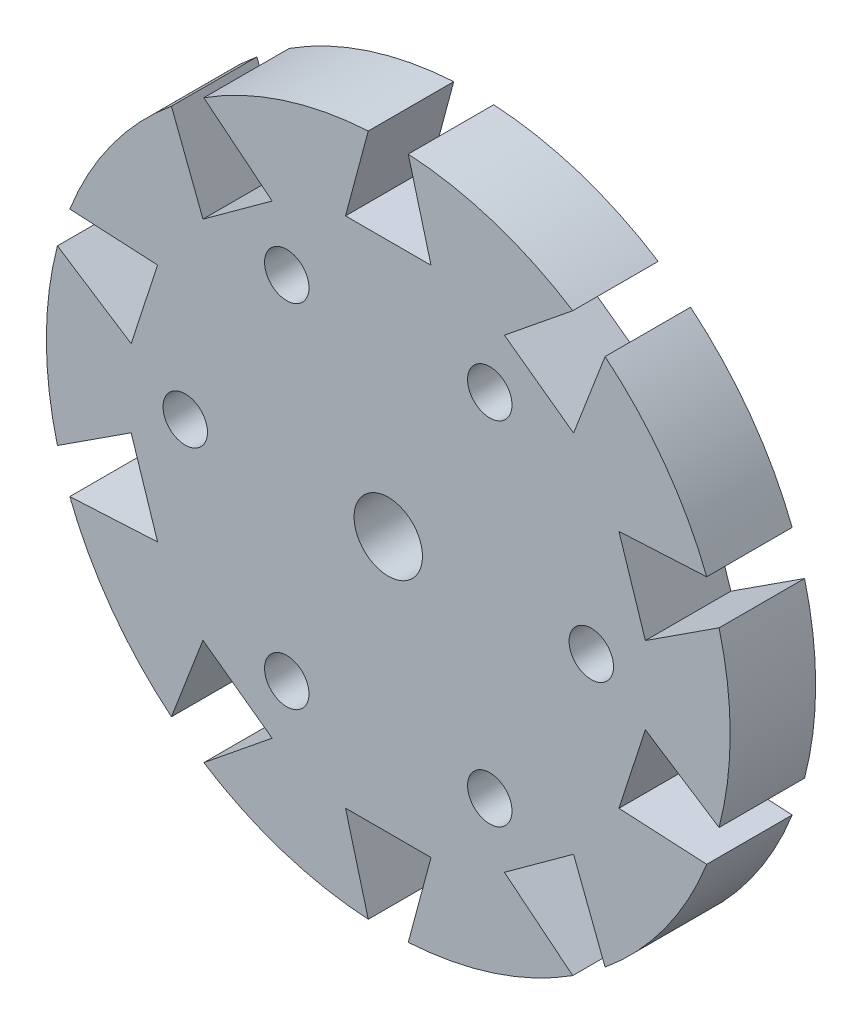
from build123d import *

# Parameters (mm, degrees)
SKETCH1_R           = 40
SKETCH1_R_2         = 4
SKETCH1_R_3         = 2.6
BOSS_EXTRUDE1_DEPTH = 10
CUT_EXTRUDE1_START  = -11
CUT_EXTRUDE1_DEPTH  = 12
CIRPATTERN1_COUNT   = 10


with BuildPart() as part:
    # Sketch1 → Boss-Extrude1 (new body)
    with BuildSketch(Plane.XY):
        Circle(SKETCH1_R)
        Circle(SKETCH1_R_2, mode=Mode.SUBTRACT)
        with Locations((-23.75, 0)):
            Circle(SKETCH1_R_3, mode=Mode.SUBTRACT)
        with Locations((-11.875, 20.56810334)):
            Circle(SKETCH1_R_3, mode=Mode.SUBTRACT)
        with Locations((11.875, 20.56810334)):
            Circle(SKETCH1_R_3, mode=Mode.SUBTRACT)
        with Locations((23.75, 0)):
            Circle(SKETCH1_R_3, mode=Mode.SUBTRACT)
        with Locations((11.875, -20.56810334)):
            Circle(SKETCH1_R_3, mode=Mode.SUBTRACT)
        with Locations((-11.875, -20.56810334)):
            Circle(SKETCH1_R_3, mode=Mode.SUBTRACT)
    extrude(amount=BOSS_EXTRUDE1_DEPTH)

    # Sketch3 → Cut-Extrude1 (cut)
    with BuildSketch(Plane.XY.offset(10).offset(CUT_EXTRUDE1_START)):
        Polygon((47.070941398, 224.331398897), (-2.338845452, 39.931563981), (-5, 30), (5, 30), (2.338845452, 39.931563981), (-47.070941398, 224.331398897), (-47.070941398, -157.478114623), (47.070941398, -157.478114623), align=None)
    cut_extrude1 = extrude(amount=CUT_EXTRUDE1_DEPTH, mode=Mode.SUBTRACT)

    # CirPattern1: Cut-Extrude1 ×10 about axis
    cirpattern1_axis = Axis((0, 0, 10), (0, 0, 1))
    for i in range(1, CIRPATTERN1_COUNT):
        add(cut_extrude1.rotate(cirpattern1_axis, i * 360 / CIRPATTERN1_COUNT), mode=Mode.SUBTRACT)


solid = part.part
